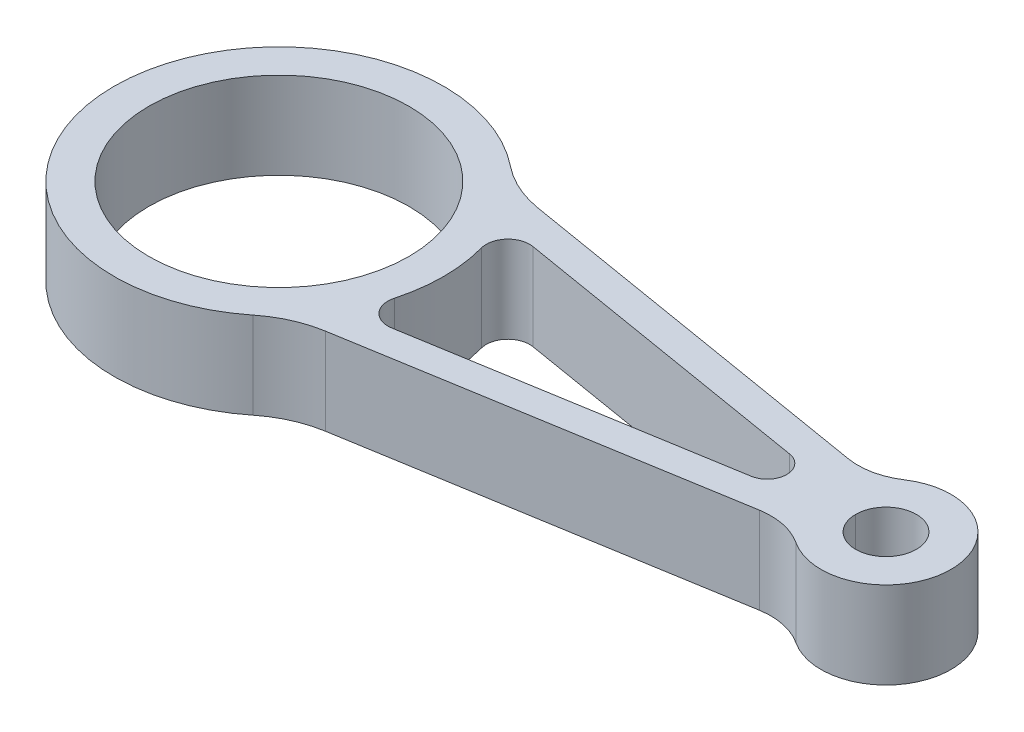
from build123d import *

# Parameters (mm, degrees)
SKETCH1_R           = 30
SKETCH1_R_2         = 7
BOSS_EXTRUDE1_DEPTH = 10
FILLET1_R           = 15
FILLET2_R           = 25
CUT_EXTRUDE1_DEPTH  = 21


with BuildPart() as part:
    # Sketch1 → Boss-Extrude1 (new body, symmetric)
    with BuildSketch(Plane(origin=(0, 0, 0), x_dir=(1, 0, 0), z_dir=(0, 1, 0))):
        with BuildLine():
            Line((27.935473676, 25.760615491), (128.063755469, 9.084385863))
            ThreePointArc((128.063755469, 9.084385863), (155, 0), (128.063755469, -9.084385863))
            Line((128.063755469, -9.084385863), (27.935473676, -25.760615491))
            ThreePointArc((27.935473676, -25.760615491), (-38, 0), (27.935473676, 25.760615491))
        make_face()
        Circle(SKETCH1_R, mode=Mode.SUBTRACT)
        with Locations((140, 0)):
            Circle(SKETCH1_R_2, mode=Mode.SUBTRACT)
    extrude(amount=BOSS_EXTRUDE1_DEPTH, both=True)

    # Fillet1
    fillet1_edges = [part.edges().sort_by_distance(p)[0] for p in [
        (128.063755469, 0, -9.084385863),
        (128.063755469, 0, 9.084385863),
    ]]
    fillet(fillet1_edges, radius=FILLET1_R)

    # Fillet2
    fillet2_edges = [part.edges().sort_by_distance(p)[0] for p in [
        (27.935473676, 0, -25.760615491),
        (27.935473676, 0, 25.760615491),
    ]]
    fillet(fillet2_edges, radius=FILLET2_R)

    # Sketch2 → Cut-Extrude1 (cut, through all)
    with BuildSketch(Plane.XZ.offset(10)):
        with BuildLine():
            Line((42.299222529, 16.271932074), (113.347981366, 4.438857582))
            ThreePointArc((113.347981366, 4.438857582), (117.108695652, 0), (113.347981366, -4.438857582))
            Line((113.347981366, -4.438857582), (42.299222529, -16.271932074))
            ThreePointArc((42.299222529, -16.271932074), (37.766889928, -14.690866644), (36.65479466, -10.021278781))
            ThreePointArc((36.65479466, -10.021278781), (38, 0), (36.65479466, 10.021278781))
            ThreePointArc((36.65479466, 10.021278781), (37.766889928, 14.690866644), (42.299222529, 16.271932074))
        make_face()
    extrude(amount=-CUT_EXTRUDE1_DEPTH, mode=Mode.SUBTRACT)


solid = part.part
